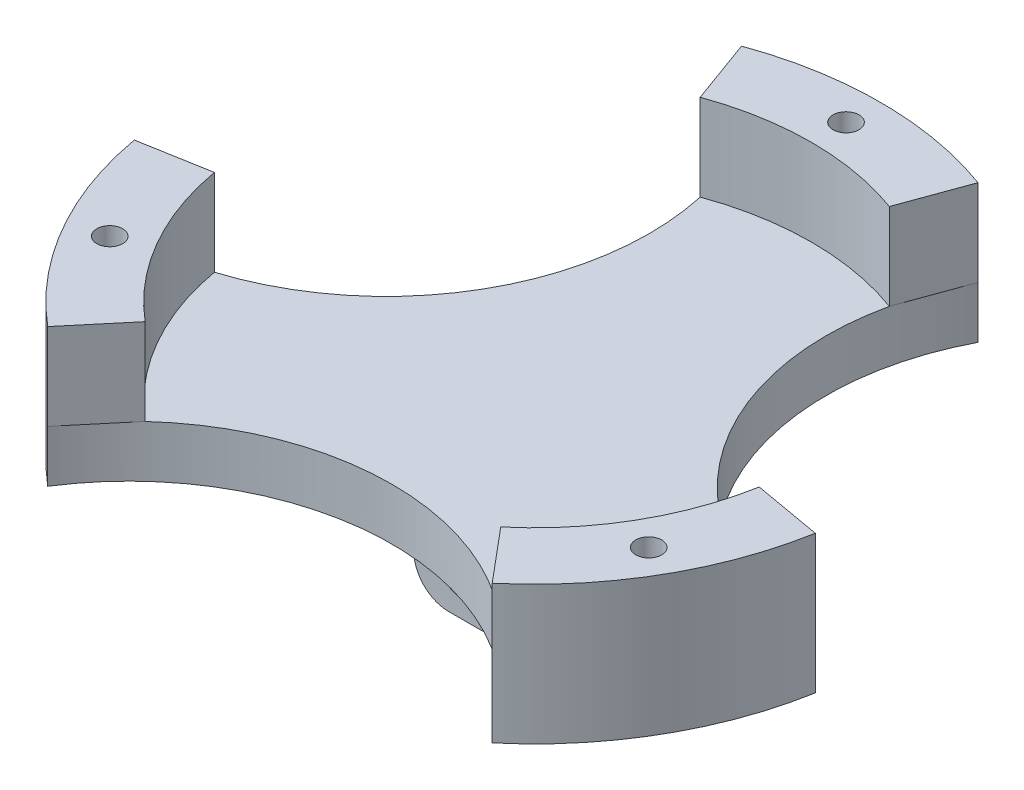
from build123d import *

# Parameters (mm, degrees)
SKETCH1_R                = 40
BOSS_EXTRUDE1_DEPTH      = 6
SKETCH2_R                = 1.5
BOSS_EXTRUDE2_DEPTH      = 10
SKETCH16_R               = 1.5
CUT_EXTRUDE9_DEPTH       = 17
CIRPATTERN1_COUNT        = 3
SKETCH5_R                = 30.471270003
CUT_EXTRUDE3_DEPTH       = 7
CIRPATTERN2_COUNT        = 3
SKETCH17_W               = 12
SKETCH17_H               = 16
BOSS_EXTRUDE3_DEPTH      = 12
FILLET1_R                = 4
FILLET2_R                = 4
SKETCH18_R               = 4
CUT_EXTRUDE10_DEPTH      = 23.641777725
CUT_EXTRUDE10_DEPTH_BACK = 49


with BuildPart() as part:
    # Sketch1 → Boss-Extrude1 (new body)
    with BuildSketch(Plane(origin=(0, 0, 0), x_dir=(1, 0, 0), z_dir=(0, 1, 0))):
        Circle(SKETCH1_R)
    extrude(amount=BOSS_EXTRUDE1_DEPTH)

    # Sketch2 → Boss-Extrude2 (add)
    with BuildSketch(Plane(origin=(0, 6, 0), x_dir=(1, 0, 0), z_dir=(0, 1, 0))):
        with BuildLine():
            Line((-13.680805733, 37.587704831), (-10.944644586, 30.070163865))
            ThreePointArc((-10.944644586, 30.070163865), (0, 32), (10.944644586, 30.070163865))
            Line((10.944644586, 30.070163865), (13.680805733, 37.587704831))
            ThreePointArc((13.680805733, 37.587704831), (0, 40), (-13.680805733, 37.587704831))
        make_face()
        with Locations((0, 36)):
            Circle(SKETCH2_R, mode=Mode.SUBTRACT)
    boss_extrude2 = extrude(amount=BOSS_EXTRUDE2_DEPTH)

    # Sketch16 → Cut-Extrude9 (cut, through all)
    with BuildSketch(Plane(origin=(0, 16, 0), x_dir=(1, 0, 0), z_dir=(0, 1, 0))):
        with Locations((0, 36)):
            Circle(SKETCH16_R)
    cut_extrude9 = extrude(amount=-CUT_EXTRUDE9_DEPTH, mode=Mode.SUBTRACT)

    # CirPattern1: Boss-Extrude2, Cut-Extrude9 ×3 about axis
    cirpattern1_axis = Axis((0, 0, 0), (0, 1, 0))
    for i in range(1, CIRPATTERN1_COUNT):
        add(boss_extrude2.rotate(cirpattern1_axis, i * 360 / CIRPATTERN1_COUNT))
        add(cut_extrude9.rotate(cirpattern1_axis, i * 360 / CIRPATTERN1_COUNT), mode=Mode.SUBTRACT)

    # Sketch5 → Cut-Extrude3 (cut, through all)
    with BuildSketch(Plane(origin=(0, 6, 0), x_dir=(1, 0, 0), z_dir=(0, 1, 0))):
        with Locations((40.698571494, 23.497331208)):
            Circle(SKETCH5_R)
    cut_extrude3 = extrude(amount=-CUT_EXTRUDE3_DEPTH, mode=Mode.SUBTRACT)

    # CirPattern2: Cut-Extrude3 ×3 about axis
    cirpattern2_axis = Axis((0, 0, 0), (0, 1, 0))
    for i in range(1, CIRPATTERN2_COUNT):
        add(cut_extrude3.rotate(cirpattern2_axis, i * 360 / CIRPATTERN2_COUNT), mode=Mode.SUBTRACT)

    # Sketch17 → Boss-Extrude3 (add)
    with BuildSketch(Plane.XZ):
        Rectangle(SKETCH17_W, SKETCH17_H)
    extrude(amount=BOSS_EXTRUDE3_DEPTH)

    # Fillet1
    fillet1_edges = [part.edges().sort_by_distance(p)[0] for p in [
        (-6, 0, 0),
        (6, 0, 0),
        (-6, -12, 0),
        (6, -12, 0),
    ]]
    fillet(fillet1_edges, radius=FILLET1_R)

    # Fillet2
    fillet2_edges = [part.edges().sort_by_distance(p)[0] for p in [
        (0, 0, 8),
        (0, 0, -8),
    ]]
    fillet(fillet2_edges, radius=FILLET2_R)

    # Sketch18 → Cut-Extrude10 (cut, two sides)
    with BuildSketch(Plane.XY.offset(8)) as cut_extrude10_sk:
        with Locations((0, -6)):
            Circle(SKETCH18_R)
    extrude(amount=CUT_EXTRUDE10_DEPTH, mode=Mode.SUBTRACT)
    extrude(cut_extrude10_sk.sketch, amount=-CUT_EXTRUDE10_DEPTH_BACK, mode=Mode.SUBTRACT)


solid = part.part
